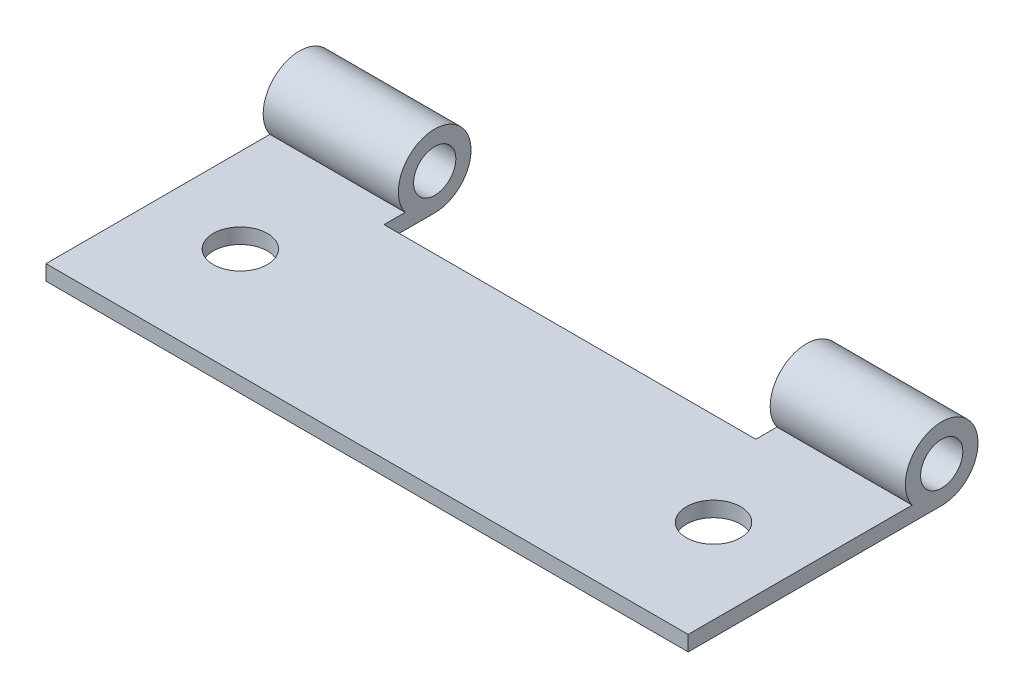
from build123d import *

# Parameters (mm, degrees)
SKETCH_1_R          = 1.25
EXTRUDE_1_DEPTH     = 38
SKETCH_2_R          = 1.6
SKETCH_2_W          = 22
SKETCH_2_H          = 7.890130192
CUT_EXTRUDE_1_DEPTH = 19


with BuildPart() as part:
    # 草图1 → 凸台-拉伸1 (new body)
    with BuildSketch(Plane(origin=(0, 0, 0), x_dir=(0, 0, -1), z_dir=(1, 0, 0))):
        with BuildLine():
            Line((0, -2.15), (-15, -2.15))
            Line((-15, -2.15), (-15, -1.25))
            Line((-15, -1.25), (-1.749285568, -1.25))
            ThreePointArc((-1.749285568, -1.25), (0.983615779, 1.911805429), (0, -2.15))
        make_face()
        Circle(SKETCH_1_R, mode=Mode.SUBTRACT)
    extrude(amount=EXTRUDE_1_DEPTH)

    # 草图2 → 切除-拉伸1 (cut, symmetric)
    with BuildSketch(Plane(origin=(0, 0, 0), x_dir=(1, 0, 0), z_dir=(0, 1, 0))):
        with Locations((33, -8.5)):
            Circle(SKETCH_2_R)
        with Locations((5, -8.5)):
            Circle(SKETCH_2_R)
        with Locations((19, 0.945065096)):
            Rectangle(SKETCH_2_W, SKETCH_2_H)
    extrude(amount=CUT_EXTRUDE_1_DEPTH, both=True, mode=Mode.SUBTRACT)


solid = part.part
